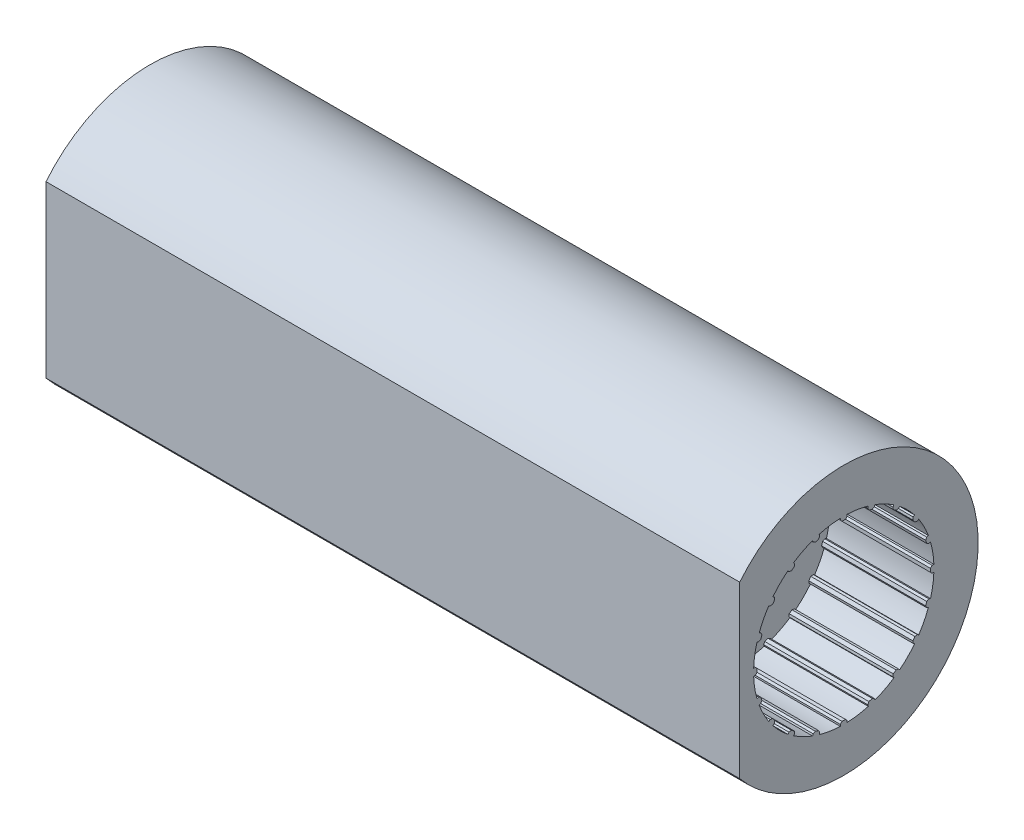
from build123d import *

# Parameters (mm, degrees)
CROQUIS1_R              = 2.25
CROQUIS1_R_2            = 1.25
SALIENTE_EXTRUIR1_DEPTH = 20
CORTAR_EXTRUIR2_DEPTH   = 3
CROQUIS1_3_R            = 2.25
CROQUIS1_3_R_2          = 1.25
CORTAR_EXTRUIR1_DEPTH   = 15.5
CROQUIS1_5_R            = 1.25
CORTAR_EXTRUIR4_DEPTH   = 17


with BuildPart() as part:
    # Croquis1 → Saliente-Extruir1 (new body)
    with BuildSketch(Plane.YZ):
        with BuildLine():
            Line((2.452677109, 3), (-2.452677109, 3))
            ThreePointArc((-2.452677109, 3), (0, -3.875), (2.452677109, 3))
        make_face()
        Circle(CROQUIS1_R, mode=Mode.SUBTRACT)
        Circle(CROQUIS1_R)
        Circle(CROQUIS1_R_2, mode=Mode.SUBTRACT)
        Circle(CROQUIS1_R_2)
    extrude(amount=SALIENTE_EXTRUIR1_DEPTH)

    # Croquis2 → Cortar-Extruir2 (cut)
    with BuildSketch(Plane.YZ.offset(20)):
        with BuildLine():
            Line((-2.498076211, 0.05), (-2.498076211, 0))
            Line((-2.498076211, 0), (-2.498076211, -0.05))
            Line((-2.498076211, -0.05), (-2.548076211, -0.1))
            Line((-2.548076211, -0.1), (-2.598076211, -0.1))
            ThreePointArc((-2.598076211, -0.1), (-2.567989686, -0.406729609), (-2.50181901, -0.70774405))
            Line((-2.50181901, -0.70774405), (-2.454266184, -0.692293201))
            Line((-2.454266184, -0.692293201), (-2.391262509, -0.724395177))
            Line((-2.391262509, -0.724395177), (-2.375811659, -0.771948003))
            Line((-2.375811659, -0.771948003), (-2.360360809, -0.819500828))
            Line((-2.360360809, -0.819500828), (-2.392462785, -0.882504504))
            Line((-2.392462785, -0.882504504), (-2.440015611, -0.897955354))
            ThreePointArc((-2.440015611, -0.897955354), (-2.316616963, -1.180375299), (-2.160666333, -1.446209182))
            Line((-2.160666333, -1.446209182), (-2.120215483, -1.416819919))
            Line((-2.120215483, -1.416819919), (-2.050375371, -1.427881506))
            Line((-2.050375371, -1.427881506), (-2.020986108, -1.468332356))
            Line((-2.020986108, -1.468332356), (-1.991596846, -1.508783206))
            Line((-1.991596846, -1.508783206), (-2.002658433, -1.578623318))
            Line((-2.002658433, -1.578623318), (-2.043109282, -1.608012581))
            ThreePointArc((-2.043109282, -1.608012581), (-1.838477631, -1.838477631), (-1.608012581, -2.043109282))
            Line((-1.608012581, -2.043109282), (-1.578623318, -2.002658433))
            Line((-1.578623318, -2.002658433), (-1.508783206, -1.991596846))
            Line((-1.508783206, -1.991596846), (-1.468332356, -2.020986108))
            Line((-1.468332356, -2.020986108), (-1.427881506, -2.050375371))
            Line((-1.427881506, -2.050375371), (-1.416819919, -2.120215483))
            Line((-1.416819919, -2.120215483), (-1.446209182, -2.160666333))
            ThreePointArc((-1.446209182, -2.160666333), (-1.180375299, -2.316616963), (-0.897955354, -2.440015611))
            Line((-0.897955354, -2.440015611), (-0.882504504, -2.392462785))
            Line((-0.882504504, -2.392462785), (-0.819500828, -2.360360809))
            Line((-0.819500828, -2.360360809), (-0.771948003, -2.375811659))
            Line((-0.771948003, -2.375811659), (-0.724395177, -2.391262509))
            Line((-0.724395177, -2.391262509), (-0.692293201, -2.454266184))
            Line((-0.692293201, -2.454266184), (-0.70774405, -2.50181901))
            ThreePointArc((-0.70774405, -2.50181901), (-0.406729609, -2.567989686), (-0.1, -2.598076211))
            Line((-0.1, -2.598076211), (-0.1, -2.548076211))
            Line((-0.1, -2.548076211), (-0.05, -2.498076211))
            Line((-0.05, -2.498076211), (0, -2.498076211))
            Line((0, -2.498076211), (0.05, -2.498076211))
            Line((0.05, -2.498076211), (0.1, -2.548076211))
            Line((0.1, -2.548076211), (0.1, -2.598076211))
            ThreePointArc((0.1, -2.598076211), (0.406729609, -2.567989686), (0.70774405, -2.50181901))
            Line((0.70774405, -2.50181901), (0.692293201, -2.454266184))
            Line((0.692293201, -2.454266184), (0.724395177, -2.391262509))
            Line((0.724395177, -2.391262509), (0.771948003, -2.375811659))
            Line((0.771948003, -2.375811659), (0.819500828, -2.360360809))
            Line((0.819500828, -2.360360809), (0.882504504, -2.392462785))
            Line((0.882504504, -2.392462785), (0.897955354, -2.440015611))
            ThreePointArc((0.897955354, -2.440015611), (1.180375299, -2.316616963), (1.446209182, -2.160666333))
            Line((1.446209182, -2.160666333), (1.416819919, -2.120215483))
            Line((1.416819919, -2.120215483), (1.427881506, -2.050375371))
            Line((1.427881506, -2.050375371), (1.468332356, -2.020986108))
            Line((1.468332356, -2.020986108), (1.508783206, -1.991596846))
            Line((1.508783206, -1.991596846), (1.578623318, -2.002658433))
            Line((1.578623318, -2.002658433), (1.608012581, -2.043109282))
            ThreePointArc((1.608012581, -2.043109282), (1.838477631, -1.838477631), (2.043109282, -1.608012581))
            Line((2.043109282, -1.608012581), (2.002658433, -1.578623318))
            Line((2.002658433, -1.578623318), (1.991596846, -1.508783206))
            Line((1.991596846, -1.508783206), (2.020986108, -1.468332356))
            Line((2.020986108, -1.468332356), (2.050375371, -1.427881506))
            Line((2.050375371, -1.427881506), (2.120215483, -1.416819919))
            Line((2.120215483, -1.416819919), (2.160666333, -1.446209182))
            ThreePointArc((2.160666333, -1.446209182), (2.316616963, -1.180375299), (2.440015611, -0.897955354))
            Line((2.440015611, -0.897955354), (2.392462785, -0.882504504))
            Line((2.392462785, -0.882504504), (2.360360809, -0.819500828))
            Line((2.360360809, -0.819500828), (2.375811659, -0.771948003))
            Line((2.375811659, -0.771948003), (2.391262509, -0.724395177))
            Line((2.391262509, -0.724395177), (2.454266184, -0.692293201))
            Line((2.454266184, -0.692293201), (2.50181901, -0.70774405))
            ThreePointArc((2.50181901, -0.70774405), (2.567989686, -0.406729609), (2.598076211, -0.1))
            Line((2.598076211, -0.1), (2.548076211, -0.1))
            Line((2.548076211, -0.1), (2.498076211, -0.05))
            Line((2.498076211, -0.05), (2.498076211, 0))
            Line((2.498076211, 0), (2.498076211, 0.05))
            Line((2.498076211, 0.05), (2.548076211, 0.1))
            Line((2.548076211, 0.1), (2.598076211, 0.1))
            ThreePointArc((2.598076211, 0.1), (2.567989686, 0.406729609), (2.50181901, 0.70774405))
            Line((2.50181901, 0.70774405), (2.454266184, 0.692293201))
            Line((2.454266184, 0.692293201), (2.391262509, 0.724395177))
            Line((2.391262509, 0.724395177), (2.375811659, 0.771948003))
            Line((2.375811659, 0.771948003), (2.360360809, 0.819500828))
            Line((2.360360809, 0.819500828), (2.392462785, 0.882504504))
            Line((2.392462785, 0.882504504), (2.440015611, 0.897955354))
            ThreePointArc((2.440015611, 0.897955354), (2.316616963, 1.180375299), (2.160666333, 1.446209182))
            Line((2.160666333, 1.446209182), (2.120215483, 1.416819919))
            Line((2.120215483, 1.416819919), (2.050375371, 1.427881506))
            Line((2.050375371, 1.427881506), (2.020986108, 1.468332356))
            Line((2.020986108, 1.468332356), (1.991596846, 1.508783206))
            Line((1.991596846, 1.508783206), (2.002658433, 1.578623318))
            Line((2.002658433, 1.578623318), (2.043109282, 1.608012581))
            ThreePointArc((2.043109282, 1.608012581), (1.838477631, 1.838477631), (1.608012581, 2.043109282))
            Line((1.608012581, 2.043109282), (1.578623318, 2.002658433))
            Line((1.578623318, 2.002658433), (1.508783206, 1.991596846))
            Line((1.508783206, 1.991596846), (1.468332356, 2.020986108))
            Line((1.468332356, 2.020986108), (1.427881506, 2.050375371))
            Line((1.427881506, 2.050375371), (1.416819919, 2.120215483))
            Line((1.416819919, 2.120215483), (1.446209182, 2.160666333))
            ThreePointArc((1.446209182, 2.160666333), (1.180375299, 2.316616963), (0.897955354, 2.440015611))
            Line((0.897955354, 2.440015611), (0.882504504, 2.392462785))
            Line((0.882504504, 2.392462785), (0.819500828, 2.360360809))
            Line((0.819500828, 2.360360809), (0.771948003, 2.375811659))
            Line((0.771948003, 2.375811659), (0.724395177, 2.391262509))
            Line((0.724395177, 2.391262509), (0.692293201, 2.454266184))
            Line((0.692293201, 2.454266184), (0.70774405, 2.50181901))
            ThreePointArc((0.70774405, 2.50181901), (0.406729609, 2.567989686), (0.1, 2.598076211))
            Line((0.1, 2.598076211), (0.1, 2.548076211))
            Line((0.1, 2.548076211), (0.05, 2.498076211))
            Line((0.05, 2.498076211), (0, 2.498076211))
            Line((0, 2.498076211), (-0.05, 2.498076211))
            Line((-0.05, 2.498076211), (-0.1, 2.548076211))
            Line((-0.1, 2.548076211), (-0.1, 2.598076211))
            ThreePointArc((-0.1, 2.598076211), (-0.406729609, 2.567989686), (-0.70774405, 2.50181901))
            Line((-0.70774405, 2.50181901), (-0.692293201, 2.454266184))
            Line((-0.692293201, 2.454266184), (-0.724395177, 2.391262509))
            Line((-0.724395177, 2.391262509), (-0.771948003, 2.375811659))
            Line((-0.771948003, 2.375811659), (-0.819500828, 2.360360809))
            Line((-0.819500828, 2.360360809), (-0.882504504, 2.392462785))
            Line((-0.882504504, 2.392462785), (-0.897955354, 2.440015611))
            ThreePointArc((-0.897955354, 2.440015611), (-1.180375299, 2.316616963), (-1.446209182, 2.160666333))
            Line((-1.446209182, 2.160666333), (-1.416819919, 2.120215483))
            Line((-1.416819919, 2.120215483), (-1.427881506, 2.050375371))
            Line((-1.427881506, 2.050375371), (-1.468332356, 2.020986108))
            Line((-1.468332356, 2.020986108), (-1.508783206, 1.991596846))
            Line((-1.508783206, 1.991596846), (-1.578623318, 2.002658433))
            Line((-1.578623318, 2.002658433), (-1.608012581, 2.043109282))
            ThreePointArc((-1.608012581, 2.043109282), (-1.838477631, 1.838477631), (-2.043109282, 1.608012581))
            Line((-2.043109282, 1.608012581), (-2.002658433, 1.578623318))
            Line((-2.002658433, 1.578623318), (-1.991596846, 1.508783206))
            Line((-1.991596846, 1.508783206), (-2.020986108, 1.468332356))
            Line((-2.020986108, 1.468332356), (-2.050375371, 1.427881506))
            Line((-2.050375371, 1.427881506), (-2.120215483, 1.416819919))
            Line((-2.120215483, 1.416819919), (-2.160666333, 1.446209182))
            ThreePointArc((-2.160666333, 1.446209182), (-2.316616963, 1.180375299), (-2.440015611, 0.897955354))
            Line((-2.440015611, 0.897955354), (-2.392462785, 0.882504504))
            Line((-2.392462785, 0.882504504), (-2.360360809, 0.819500828))
            Line((-2.360360809, 0.819500828), (-2.375811659, 0.771948003))
            Line((-2.375811659, 0.771948003), (-2.391262509, 0.724395177))
            Line((-2.391262509, 0.724395177), (-2.454266184, 0.692293201))
            Line((-2.454266184, 0.692293201), (-2.50181901, 0.70774405))
            ThreePointArc((-2.50181901, 0.70774405), (-2.567989686, 0.406729609), (-2.598076211, 0.1))
            Line((-2.598076211, 0.1), (-2.548076211, 0.1))
            Line((-2.548076211, 0.1), (-2.498076211, 0.05))
        make_face()
    extrude(amount=-CORTAR_EXTRUIR2_DEPTH, mode=Mode.SUBTRACT)

    # Croquis1_3 → Cortar-Extruir1 (cut)
    with BuildSketch(Plane.YZ):
        with Locations(Location((0, 0, 0), (0, 0, 90))):
            Circle(CROQUIS1_3_R)
        with Locations(Location((0, 0, 0), (0, 0, 90))):
            Circle(CROQUIS1_3_R_2, mode=Mode.SUBTRACT)
    extrude(amount=CORTAR_EXTRUIR1_DEPTH, mode=Mode.SUBTRACT)

    # Croquis1_5 → Cortar-Extruir4 (cut)
    with BuildSketch(Plane.YZ):
        with Locations(Location((0, 0, 0), (0, 0, 270))):
            Circle(CROQUIS1_5_R)
    extrude(amount=CORTAR_EXTRUIR4_DEPTH, mode=Mode.SUBTRACT)


solid = part.part
